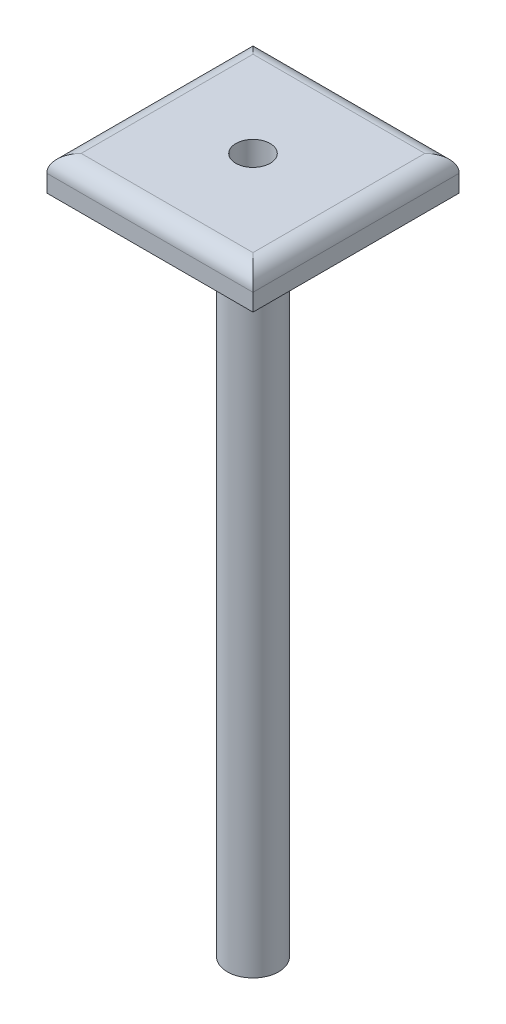
from build123d import *

# Parameters (mm, degrees)
SKETCH1_W           = 30.48
SKETCH1_H           = 30.48
BOSS_EXTRUDE1_DEPTH = 5.08
FILLET1_R           = 2.54
SKETCH2_R           = 3.81
BOSS_EXTRUDE2_DEPTH = 97.79
SKETCH3_R           = 2.54
CUT_EXTRUDE1_DEPTH  = 101.6


with BuildPart() as part:
    # Sketch1 → Boss-Extrude1 (new body)
    with BuildSketch(Plane(origin=(0, 0, 0), x_dir=(1, 0, 0), z_dir=(0, 1, 0))):
        Rectangle(SKETCH1_W, SKETCH1_H)
    extrude(amount=BOSS_EXTRUDE1_DEPTH)

    # Fillet1
    fillet1_edges = [part.edges().sort_by_distance(p)[0] for p in [
        (-15.24, 5.08, 0),
        (0, 5.08, 15.24),
        (15.24, 5.08, 0),
        (0, 5.08, -15.24),
    ]]
    fillet(fillet1_edges, radius=FILLET1_R)

    # Sketch2 → Boss-Extrude2 (add)
    with BuildSketch(Plane.XZ):
        Circle(SKETCH2_R)
    extrude(amount=BOSS_EXTRUDE2_DEPTH)

    # Sketch3 → Cut-Extrude1 (cut)
    with BuildSketch(Plane(origin=(0, 5.08, 0), x_dir=(1, 0, 0), z_dir=(0, 1, 0))):
        Circle(SKETCH3_R)
    extrude(amount=-CUT_EXTRUDE1_DEPTH, mode=Mode.SUBTRACT)


solid = part.part
